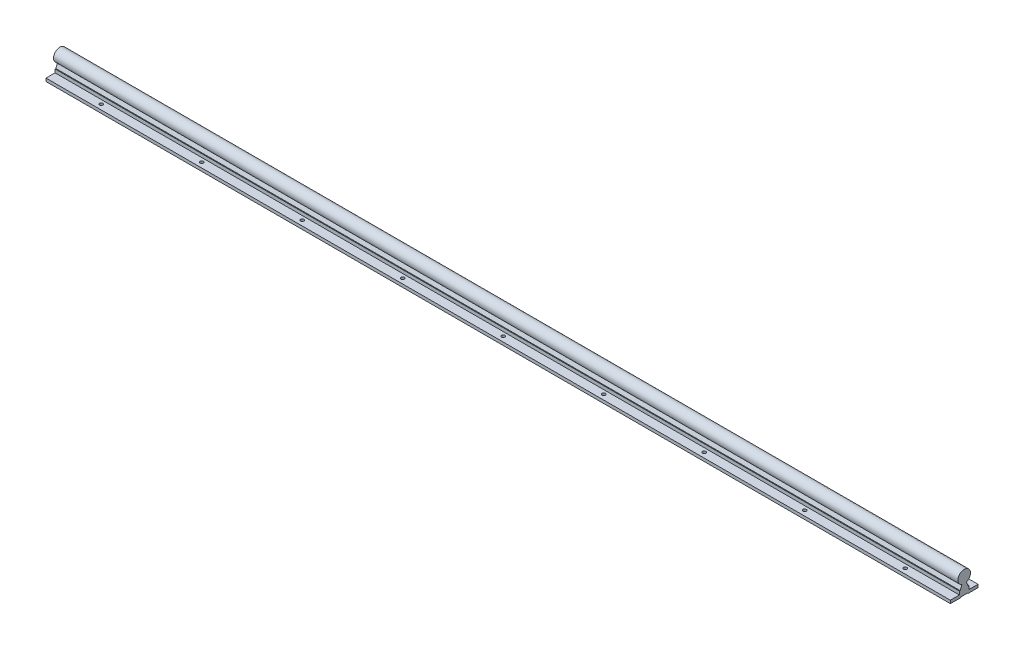
from build123d import *

# Parameters (mm, degrees)
EXTRUDE_1_DEPTH         = 1800
HOLE_WIZARD_6_6_6_6_1_D = 6.6
PATTERN_LINEAR_1_COUNT  = 9
PATTERN_LINEAR_1_PITCH  = 200


with BuildPart() as part:
    # 草图1 → 凸台-拉伸1 (new body)
    with BuildSketch(Plane(origin=(0, 0, 0), x_dir=(0, 0, -1), z_dir=(1, 0, 0))):
        with BuildLine():
            Line((38.023703704, 12.710240583), (38.023703704, 6.710240583))
            Line((38.023703704, 6.710240583), (18.023703704, 6.710240583))
            Line((18.023703704, 6.710240583), (16.823703704, 7.910240583))
            Line((16.823703704, 7.910240583), (4.223703704, 7.910240583))
            Line((4.223703704, 7.910240583), (3.023703704, 6.710240583))
            Line((3.023703704, 6.710240583), (-16.976296296, 6.710240583))
            Line((-16.976296296, 6.710240583), (-16.976296296, 12.710240583))
            Line((-16.976296296, 12.710240583), (1.023703704, 12.710240583))
            Line((1.023703704, 12.710240583), (1.023703704, 19.410240583))
            Line((1.023703704, 19.410240583), (2.593703704, 19.410240583))
            Line((2.593703704, 19.410240583), (5.975416608, 28.06708446))
            ThreePointArc((5.975416608, 28.06708446), (10.523703704, 52.210240583), (15.0719908, 28.06708446))
            Line((15.0719908, 28.06708446), (18.453703704, 19.410240583))
            Line((18.453703704, 19.410240583), (20.023703704, 19.410240583))
            Line((20.023703704, 19.410240583), (20.023703704, 12.710240583))
            Line((20.023703704, 12.710240583), (38.023703704, 12.710240583))
        make_face()
    extrude(amount=EXTRUDE_1_DEPTH)

    # Ø6.6 (6.6) 直径孔1 (through all)
    with Locations(Plane(origin=(100, 12.710240583, -28.023703704), x_dir=(0, 0, 1), z_dir=(0, 1, 0))):
        with Locations((0, 0), (35, 0)):
            hole_wizard_6_6_6_6_1 = Hole(HOLE_WIZARD_6_6_6_6_1_D / 2)

    # 阵列(线性)1: Ø6.6 (6.6) 直径孔1 ×9
    with Locations(*[(i * PATTERN_LINEAR_1_PITCH, 0, 0) for i in range(1, PATTERN_LINEAR_1_COUNT)]):
        add(hole_wizard_6_6_6_6_1, mode=Mode.SUBTRACT)


solid = part.part
